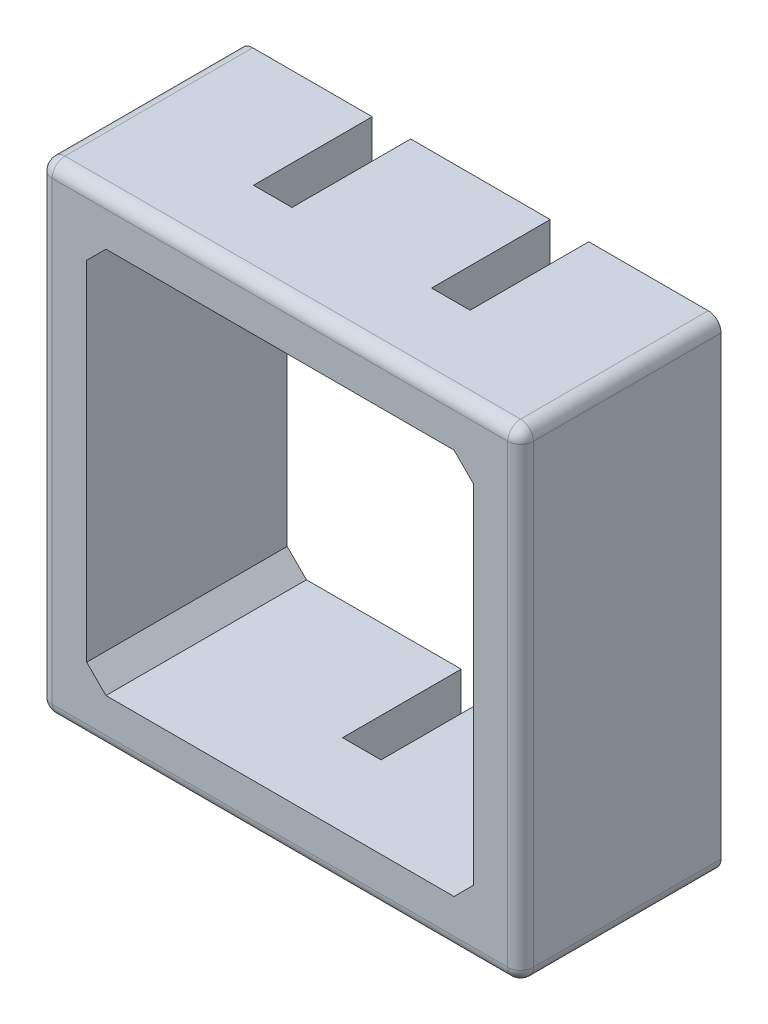
from build123d import *

# Parameters (mm, degrees)
SKETCH1_W                 = 19.05
SKETCH1_H                 = 19.05
SKETCH1_W_2               = 15.3035
SKETCH1_H_2               = 15.3035
BOSS_EXTRUDE1_DEPTH       = 7.9375
SKETCH2_W                 = 1.524
SKETCH2_H                 = 1.87325
CUT_EXTRUDE_THIN1_DEPTH   = 4.699
FILLET2_R                 = 0.508
CHAMFER1_SIZE             = 0.762
F_0_80_TAPPED_HOLE1_D     = 1.19126
F_0_80_TAPPED_HOLE1_DEPTH = 6.35
F_0_80_TAPPED_HOLE1_TIP   = 0.357890611


with BuildPart() as part:
    # Sketch1 → Boss-Extrude1 (new body)
    with BuildSketch(Plane.XY):
        with Locations((12.7, -106.3625)):
            Rectangle(SKETCH1_W, SKETCH1_H)
        with Locations((12.7, -106.3625)):
            Rectangle(SKETCH1_W_2, SKETCH1_H_2, mode=Mode.SUBTRACT)
    extrude(amount=-BOSS_EXTRUDE1_DEPTH)

    # Sketch2 → Cut-Extrude-Thin1 (cut)
    with BuildSketch(Plane(origin=(0, 0, -7.9375), x_dir=(-1, 0, 0), z_dir=(0, 0, -1))):
        with Locations((-12.7, -114.950875)):
            Rectangle(SKETCH2_W, SKETCH2_H)
        with Locations((-9.17575, -97.774125)):
            Rectangle(SKETCH2_W, SKETCH2_H)
        with Locations((-16.22425, -97.774125)):
            Rectangle(SKETCH2_W, SKETCH2_H)
    extrude(amount=-CUT_EXTRUDE_THIN1_DEPTH, mode=Mode.SUBTRACT)

    # Fillet2
    fillet2_edges = [part.edges().sort_by_distance(p)[0] for p in [
        (12.7, -96.8375, 0),
        (22.225, -106.3625, 0),
        (12.7, -115.8875, 0),
        (3.175, -106.3625, 0),
        (3.175, -96.8375, -3.96875),
        (22.225, -96.8375, -3.96875),
        (22.225, -115.8875, -3.96875),
        (3.175, -115.8875, -3.96875),
    ]]
    fillet(fillet2_edges, radius=FILLET2_R)

    # Chamfer1
    chamfer1_edges = [part.edges().sort_by_distance(p)[0] for p in [
        (5.04825, -114.01425, -3.96875),
        (5.04825, -98.71075, -3.96875),
        (20.35175, -98.71075, -3.96875),
        (20.35175, -114.01425, -3.96875),
    ]]
    chamfer(chamfer1_edges, length=CHAMFER1_SIZE)

    # #0-80 Tapped Hole1
    with Locations(Plane(origin=(0, 0, -7.9375), x_dir=(-1, 0, 0), z_dir=(0, 0, -1))):
        with Locations((-4.376519878, -98.039019878), (-21.023480122, -114.685980122)):
            Hole(F_0_80_TAPPED_HOLE1_D / 2, depth=F_0_80_TAPPED_HOLE1_DEPTH)
            with Locations((0, 0, -(F_0_80_TAPPED_HOLE1_DEPTH + F_0_80_TAPPED_HOLE1_TIP / 2))):  # 118° drill point
                Cone(0, F_0_80_TAPPED_HOLE1_D / 2, F_0_80_TAPPED_HOLE1_TIP, mode=Mode.SUBTRACT)


solid = part.part
